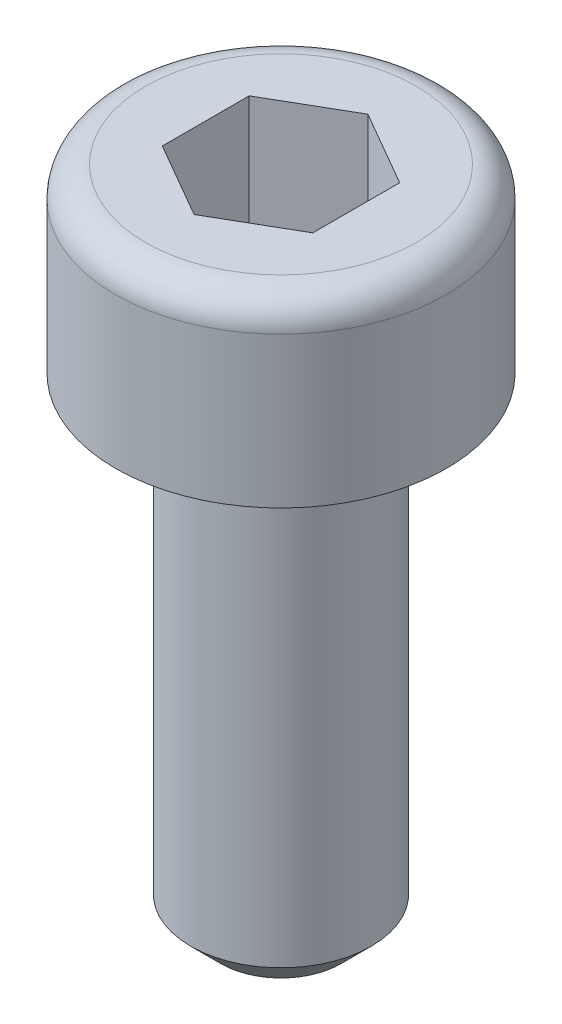
from build123d import *

# Parameters (mm, degrees)
CORTAR_EXTRUIR1_DEPTH = 2
CHAFL_N1_SIZE         = 0.5
REDONDEO1_R           = 0.5


with BuildPart() as part:
    # Croquis1 → Revolución1 (revolve)
    with BuildSketch(Plane.XY):
        Polygon((0, 0), (2.75, 0), (2.75, -3), (1.5, -3), (1.5, -11), (0, -11), align=None)
    revolve(axis=Axis((0, 0, 0), (0, -1, 0)))

    # Croquis2 → Cortar-Extruir1 (cut)
    with BuildSketch(Plane(origin=(0, 0, 0), x_dir=(1, 0, 0), z_dir=(0, 1, 0))):
        Polygon((1.25, 0.721687836), (0, 1.443375673), (-1.25, 0.721687836), (-1.25, -0.721687836), (0, -1.443375673), (1.25, -0.721687836), align=None)
    extrude(amount=-CORTAR_EXTRUIR1_DEPTH, mode=Mode.SUBTRACT)

    # Chaflán1
    chafl_n1_edges = [part.edges().sort_by_distance(p)[0] for p in [
        (-1.5, -11, 0),
    ]]
    chamfer(chafl_n1_edges, length=CHAFL_N1_SIZE)

    # Redondeo1
    redondeo1_edges = [part.edges().sort_by_distance(p)[0] for p in [
        (-2.75, 0, 0),
    ]]
    fillet(redondeo1_edges, radius=REDONDEO1_R)


solid = part.part
